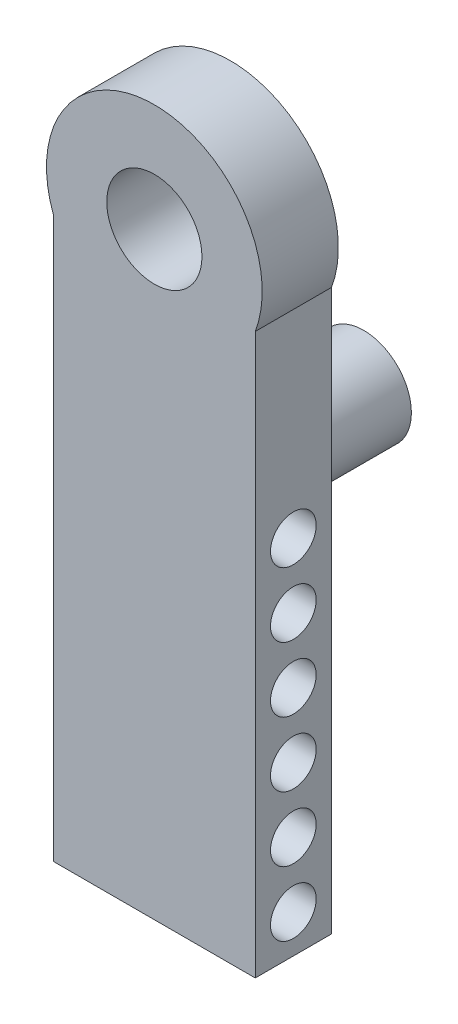
from build123d import *

# Parameters (mm, degrees)
SKETCH2_R           = 10
BOSS_EXTRUDE2_DEPTH = 20
SKETCH8_R           = 6
CUT_EXTRUDE1_DEPTH  = 55.824018077
SKETCH6_R           = 6
CUT_EXTRUDE2_DEPTH  = 55.824018077
SKETCH9_R           = 12.5
CUT_EXTRUDE3_DEPTH  = 23
SKETCH11_R          = 12.5
BOSS_EXTRUDE4_DEPTH = 35


with BuildPart() as part:
    # Sketch2 → Boss-Extrude2 (new body)
    with BuildSketch(Plane.XY):
        with BuildLine():
            Line((-37.926977186, -74.415871925), (-37.926977186, -221.455871925))
            Line((-37.926977186, -221.455871925), (-90.926977186, -221.455871925))
            Line((-90.926977186, -221.455871925), (-90.926977186, -74.415871925))
            ThreePointArc((-90.926977186, -74.415871925), (-64.426977186, -36.091853848), (-37.926977186, -74.415871925))
        make_face()
        with Locations((-64.426977186, -64.415871925)):
            Circle(SKETCH2_R, mode=Mode.SUBTRACT)
    extrude(amount=BOSS_EXTRUDE2_DEPTH)

    # Sketch8 → Cut-Extrude1 (cut, through all)
    with BuildSketch(Plane.ZY.offset(90.926977186)):
        with Locations((10, -194.455871925)):
            Circle(SKETCH8_R)
        with Locations((10, -177.455871925)):
            Circle(SKETCH8_R)
        with Locations((10, -160.455871925)):
            Circle(SKETCH8_R)
        with Locations((10, -143.455871925)):
            Circle(SKETCH8_R)
        with Locations((10, -126.455871925)):
            Circle(SKETCH8_R)
    extrude(amount=-CUT_EXTRUDE1_DEPTH, mode=Mode.SUBTRACT)

    # Sketch6 → Cut-Extrude2 (cut, through all)
    with BuildSketch(Plane.ZY.offset(90.926977186)):
        with Locations((10, -211.455871925)):
            Circle(SKETCH6_R)
    extrude(amount=-CUT_EXTRUDE2_DEPTH, mode=Mode.SUBTRACT)

    # Sketch9 → Cut-Extrude3 (cut)
    with BuildSketch(Plane.XY.offset(20)):
        with Locations((-64.426977186, -64.415871925)):
            Circle(SKETCH9_R)
    extrude(amount=-CUT_EXTRUDE3_DEPTH, mode=Mode.SUBTRACT)

    # Sketch11 → Boss-Extrude4 (add)
    with BuildSketch(Plane.XY):
        with Locations((-64.426977186, -127.415871925)):
            Circle(SKETCH11_R)
    extrude(amount=-BOSS_EXTRUDE4_DEPTH)


solid = part.part
